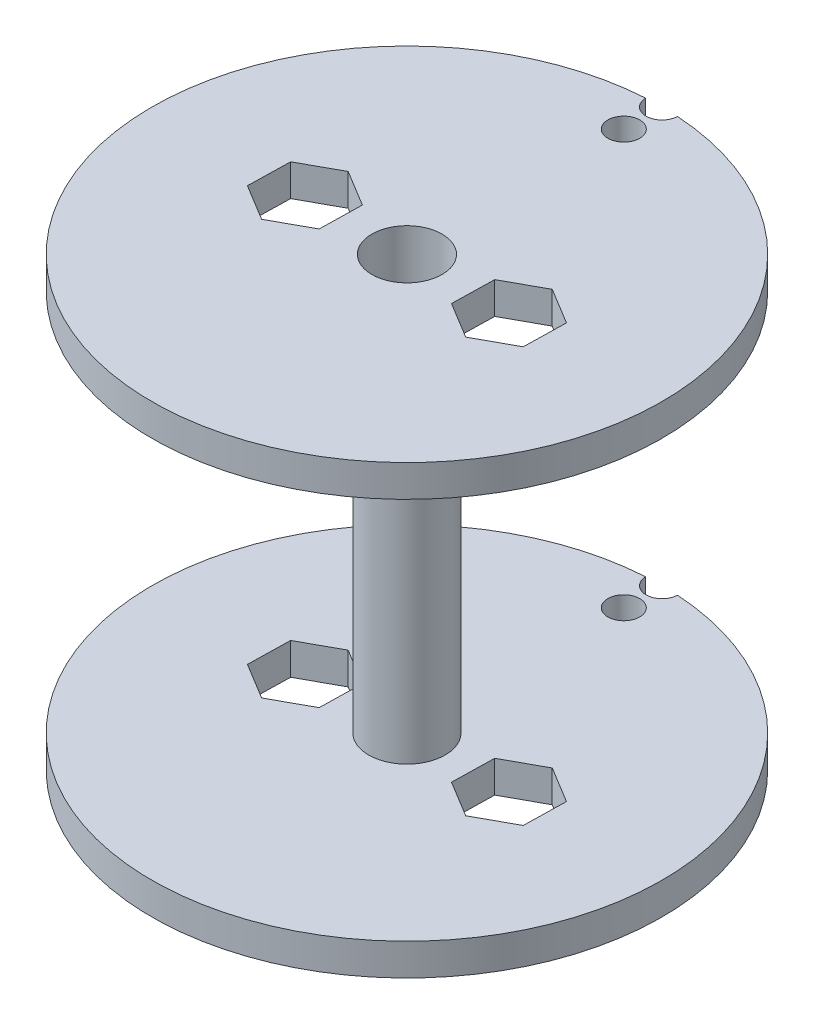
from build123d import *

# Parameters (mm, degrees)
SKETCH1_R           = 20
SKETCH1_R_2         = 2.75
BOSS_EXTRUDE1_DEPTH = 2.5
CUT_EXTRUDE3_DEPTH  = 2.5
SKETCH4_R           = 1.25
CUT_EXTRUDE4_DEPTH  = 5
SKETCH2_R           = 3
SKETCH2_R_2         = 2.75
BOSS_EXTRUDE2_DEPTH = 15


with BuildPart() as part:
    # Sketch1 → Boss-Extrude1 (new body)
    with BuildSketch(Plane(origin=(0, 0, 0), x_dir=(1, 0, 0), z_dir=(0, 1, 0))):
        Circle(SKETCH1_R)
        Circle(SKETCH1_R_2, mode=Mode.SUBTRACT)
    extrude(amount=BOSS_EXTRUDE1_DEPTH)

    # Sketch3 → Cut-Extrude3 (cut)
    with BuildSketch(Plane.XZ):
        Polygon((-5.161329605, 1.721273866), (-8.071331697, 3.318997608), (-10.910002092, 1.597723742), (-10.838670395, -1.721273866), (-7.928668303, -3.318997608), (-5.089997908, -1.597723742), align=None)
        Polygon((5.161329605, -1.721273866), (8.071331697, -3.318997608), (10.910002092, -1.597723742), (10.838670395, 1.721273866), (7.928668303, 3.318997608), (5.089997908, 1.597723742), align=None)
    extrude(amount=-CUT_EXTRUDE3_DEPTH, mode=Mode.SUBTRACT)

    # Sketch4 → Cut-Extrude4 (cut)
    with BuildSketch(Plane(origin=(0, 2.5, 0), x_dir=(1, 0, 0), z_dir=(0, 1, 0))):
        with Locations((0, 17)):
            Circle(SKETCH4_R)
        with Locations((0, 20)):
            Circle(SKETCH4_R)
    extrude(amount=-CUT_EXTRUDE4_DEPTH, mode=Mode.SUBTRACT)

    # Sketch2 → Boss-Extrude2 (add)
    with BuildSketch(Plane(origin=(0, 2.5, 0), x_dir=(1, 0, 0), z_dir=(0, 1, 0))):
        Circle(SKETCH2_R)
        Circle(SKETCH2_R_2, mode=Mode.SUBTRACT)
    extrude(amount=BOSS_EXTRUDE2_DEPTH)

    # Mirror7: part across plane


with BuildPart() as part_1:
    add(part.part)
    add(part.part.mirror(Plane.ZX.offset(17.5)))


solid = part_1.part
